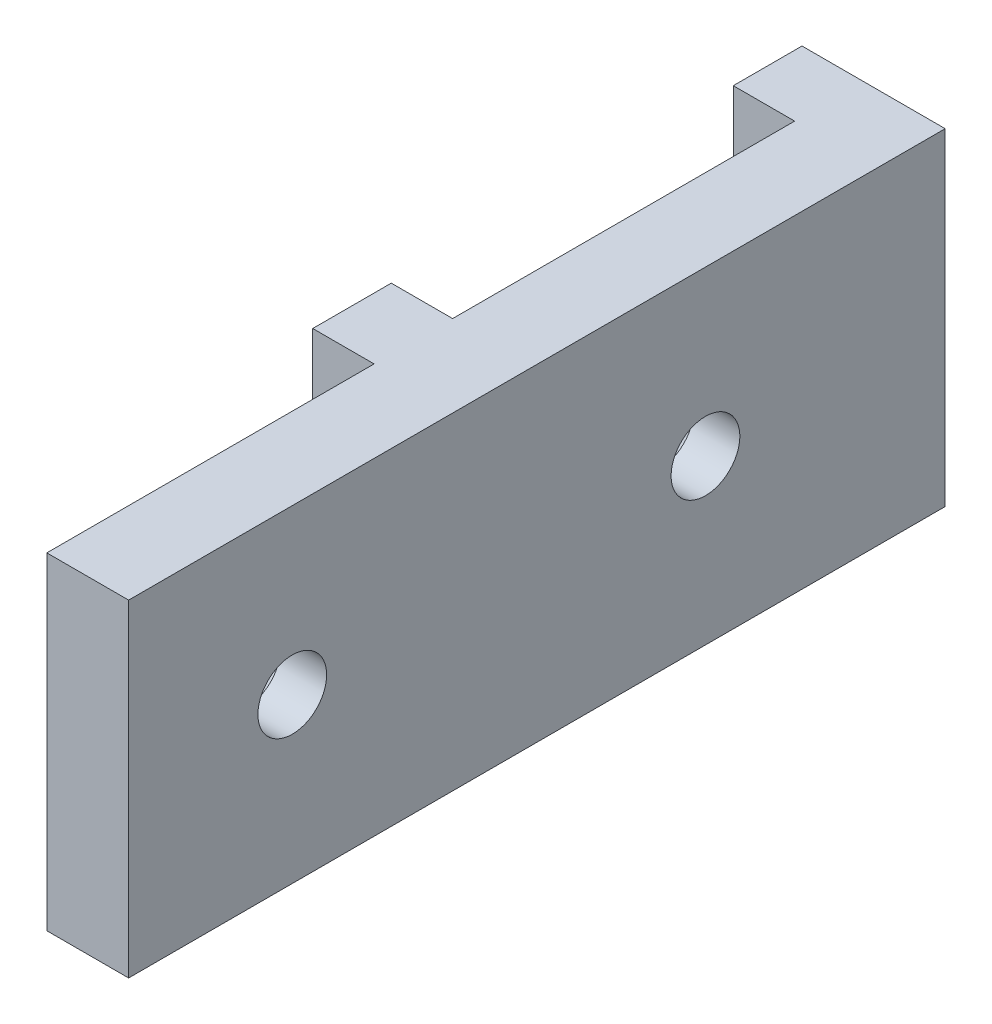
from build123d import *

# Parameters (mm, degrees)
SKETCH1_W           = 6.096
SKETCH1_H           = 25.4
BOSS_EXTRUDE1_DEPTH = 4.7625
SKETCH2_W           = 69.85
SKETCH2_H           = 25.4
BOSS_EXTRUDE2_DEPTH = 6.35
SKETCH5_W           = 5.334
SKETCH5_H           = 25.4
BOSS_EXTRUDE3_DEPTH = 4.7625
CUT_EXTRUDE3_REACH  = 8.35
SKETCH6_W           = 6.477
SKETCH6_H           = 25.4
CUT_EXTRUDE1_REACH  = 8.35
SKETCH3_R           = 2.667
SKETCH4_R           = 4.7625
CUT_EXTRUDE2_DEPTH  = 3.81
CUT_EXTRUDE2_TAPER  = 37


with BuildPart() as part:
    # Sketch1 → Boss-Extrude1 (new body)
    with BuildSketch(Plane(origin=(0, 0, 0), x_dir=(0, 0, -1), z_dir=(1, 0, 0))):
        with Locations((3.048, 12.7)):
            Rectangle(SKETCH1_W, SKETCH1_H)
    extrude(amount=BOSS_EXTRUDE1_DEPTH)

    # Sketch2 → Boss-Extrude2 (add)
    with BuildSketch(Plane(origin=(4.7625, 0, 0), x_dir=(0, 0, -1), z_dir=(1, 0, 0))):
        with Locations((3.048, 12.7)):
            Rectangle(SKETCH2_W, SKETCH2_H)
    extrude(amount=BOSS_EXTRUDE2_DEPTH)

    # Sketch5 → Boss-Extrude3 (add)
    with BuildSketch(Plane.ZY.offset(-4.7625)):
        with Locations((-35.306, 12.7)):
            Rectangle(SKETCH5_W, SKETCH5_H)
    extrude(amount=BOSS_EXTRUDE3_DEPTH)

    # Sketch6 → Cut-Extrude3 (cut, up to next)
    with BuildSketch(Plane.ZY.offset(-4.7625), mode=Mode.PRIVATE) as cut_extrude3_sk1:
        with Locations((28.6385, 12.7)):
            Rectangle(SKETCH6_W, SKETCH6_H)
    cut_extrude3_tool1 = extrude(cut_extrude3_sk1.sketch, amount=-CUT_EXTRUDE3_REACH, mode=Mode.PRIVATE) & part.part
    add(cut_extrude3_tool1.solids().sort_by_distance((4.7625, 12.7, 28.6385))[0], mode=Mode.SUBTRACT)

    # Sketch3 → Cut-Extrude1 (cut, up to next)
    with BuildSketch(Plane.ZY.offset(-4.7625), mode=Mode.PRIVATE) as cut_extrude1_sk1:
        with Locations((-19.3675, 12.7)):
            Circle(SKETCH3_R)
    cut_extrude1_tool1 = extrude(cut_extrude1_sk1.sketch, amount=-CUT_EXTRUDE1_REACH, mode=Mode.PRIVATE) & part.part
    add(cut_extrude1_tool1.solids().sort_by_distance((4.7625, 12.7, -19.3675))[0], mode=Mode.SUBTRACT)
    # Sketch3 → Cut-Extrude1 (cut, up to next)
    with BuildSketch(Plane.ZY.offset(-4.7625), mode=Mode.PRIVATE) as cut_extrude1_sk2:
        with Locations((12.7, 12.7)):
            Circle(SKETCH3_R)
    cut_extrude1_tool2 = extrude(cut_extrude1_sk2.sketch, amount=-CUT_EXTRUDE1_REACH, mode=Mode.PRIVATE) & part.part
    add(cut_extrude1_tool2.solids().sort_by_distance((4.7625, 12.7, 12.7))[0], mode=Mode.SUBTRACT)

    # Sketch4 → Cut-Extrude2 (cut)
    with BuildSketch(Plane.ZY.offset(-4.7625)):
        with Locations((12.7, 12.7)):
            Circle(SKETCH4_R)
        with Locations((-19.3675, 12.7)):
            Circle(SKETCH4_R)
    extrude(amount=-CUT_EXTRUDE2_DEPTH, taper=CUT_EXTRUDE2_TAPER, mode=Mode.SUBTRACT)


solid = part.part
